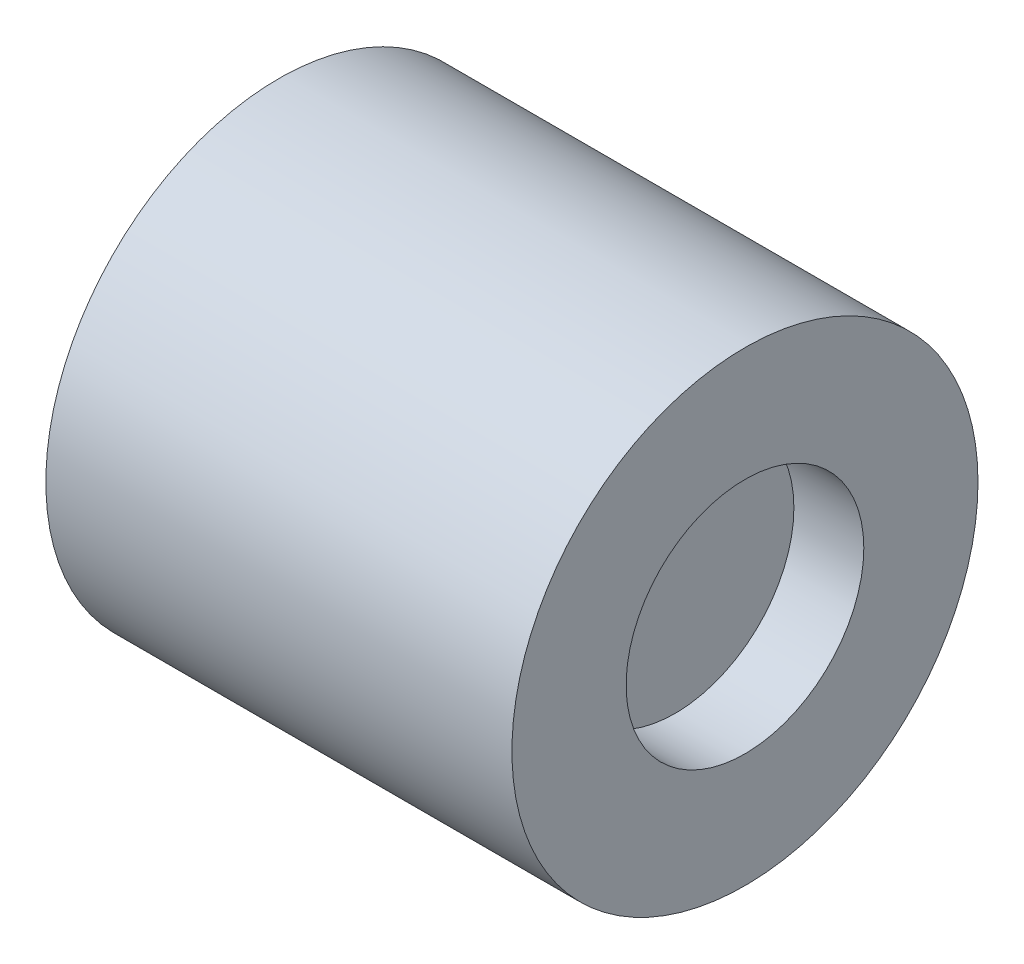
from build123d import *

# Parameters (mm, degrees)
SKETCH1_R           = 5
BOSS_EXTRUDE1_DEPTH = 10
SKETCH2_R           = 2.55
CUT_EXTRUDE1_DEPTH  = 1.5
SKETCH4_R           = 2.525
CUT_EXTRUDE2_DEPTH  = 6


with BuildPart() as part:
    # Sketch1 → Boss-Extrude1 (new body)
    with BuildSketch(Plane.YZ):
        Circle(SKETCH1_R)
    extrude(amount=BOSS_EXTRUDE1_DEPTH)

    # Sketch2 → Cut-Extrude1 (cut)
    with BuildSketch(Plane.YZ.offset(10)):
        Circle(SKETCH2_R)
    extrude(amount=-CUT_EXTRUDE1_DEPTH, mode=Mode.SUBTRACT)

    # Sketch4 → Cut-Extrude2 (cut)
    with BuildSketch(Plane(origin=(0, 0, 0), x_dir=(0, -1, 0), z_dir=(-1, 0, 0))):
        Circle(SKETCH4_R)
    extrude(amount=-CUT_EXTRUDE2_DEPTH, mode=Mode.SUBTRACT)


solid = part.part
